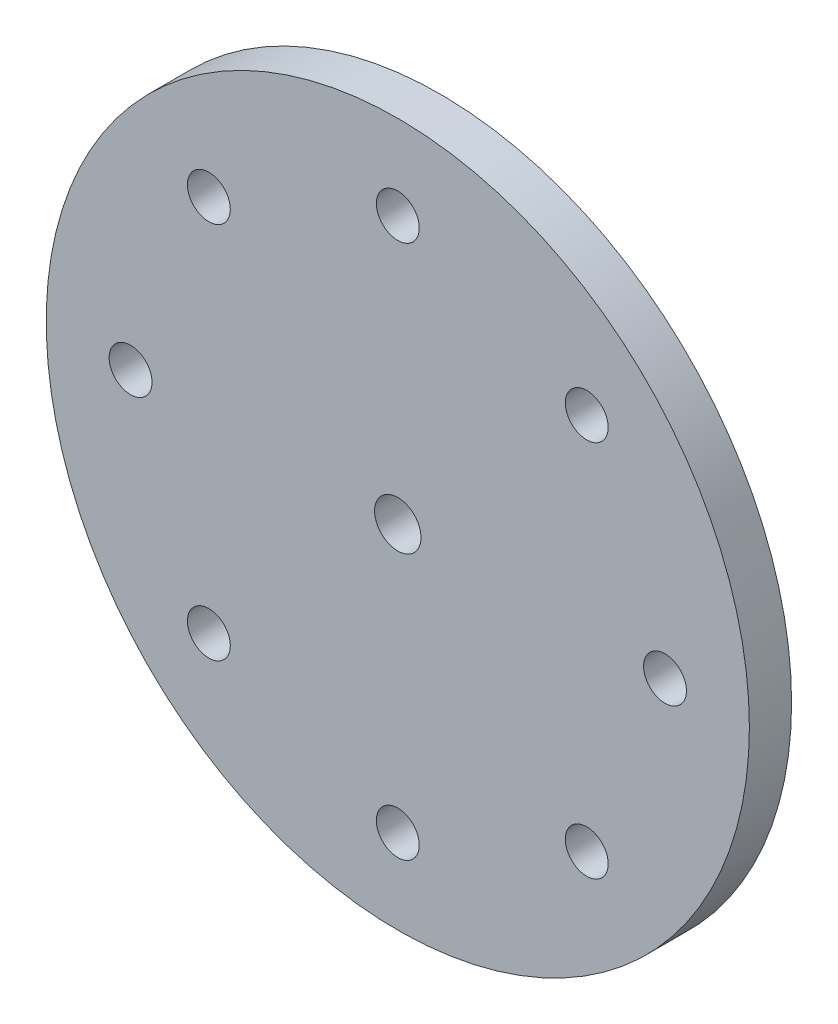
from build123d import *

# Parameters (mm, degrees)
SKETCH_1_R               = 25
SKETCH_1_R_2             = 1.525
EXTRUDE_1_DEPTH          = 3
EXTRUDE_START            = -3
SKETCH_2_R               = 4
EXTRUDE_2_DEPTH          = 11.3
SKETCH_3_R               = 5.2
EXTRUDE_3_DEPTH          = 1.2
HOLE_WIZARD_M4_1_D       = 3.3
SKETCH_6_W               = 9
SKETCH_6_H               = 2.1
CUT_EXTRUDE_1_DEPTH      = 26
CUT_EXTRUDE_1_DEPTH_BACK = 26


with BuildPart() as part:
    # 草图1 → 凸台-拉伸1 (new body)
    with BuildSketch(Plane.XY):
        Circle(SKETCH_1_R)
        with Locations((0, 19)):
            Circle(SKETCH_1_R_2, mode=Mode.SUBTRACT)
        with Locations((13.435028843, 13.435028843)):
            Circle(SKETCH_1_R_2, mode=Mode.SUBTRACT)
        with Locations((19, 0)):
            Circle(SKETCH_1_R_2, mode=Mode.SUBTRACT)
        with Locations((13.435028843, -13.435028843)):
            Circle(SKETCH_1_R_2, mode=Mode.SUBTRACT)
        with Locations((0, -19)):
            Circle(SKETCH_1_R_2, mode=Mode.SUBTRACT)
        with Locations((-13.435028843, -13.435028843)):
            Circle(SKETCH_1_R_2, mode=Mode.SUBTRACT)
        with Locations((-19, 0)):
            Circle(SKETCH_1_R_2, mode=Mode.SUBTRACT)
        with Locations((-13.435028843, 13.435028843)):
            Circle(SKETCH_1_R_2, mode=Mode.SUBTRACT)
    extrude(amount=EXTRUDE_1_DEPTH)

    # 草图2 → 凸台-拉伸2 (add)
    with BuildSketch(Plane.XY.offset(3).offset(EXTRUDE_START)):
        Circle(SKETCH_2_R)
    extrude(amount=-EXTRUDE_2_DEPTH)

    # 草图3 → 凸台-拉伸3 (add)
    with BuildSketch(Plane.XY.offset(3).offset(EXTRUDE_START)):
        Circle(SKETCH_3_R)
    extrude(amount=-EXTRUDE_3_DEPTH)

    # M4 螺纹孔1 (through all)
    with Locations(Plane(origin=(0, 0, -11.3), x_dir=(-1, 0, 0), z_dir=(0, 0, -1))):
        with Locations((0, 0)):
            Hole(HOLE_WIZARD_M4_1_D / 2)

    # 草图6 → 切除-拉伸1 (cut, two sides)
    with BuildSketch(Plane(origin=(0, 0, 0), x_dir=(1, 0, 0), z_dir=(0, 1, 0))) as cut_extrude_1_sk:
        with Locations((-0.5, 10.25)):
            Rectangle(SKETCH_6_W, SKETCH_6_H)
    extrude(amount=CUT_EXTRUDE_1_DEPTH, mode=Mode.SUBTRACT)
    extrude(cut_extrude_1_sk.sketch, amount=-CUT_EXTRUDE_1_DEPTH_BACK, mode=Mode.SUBTRACT)


solid = part.part
